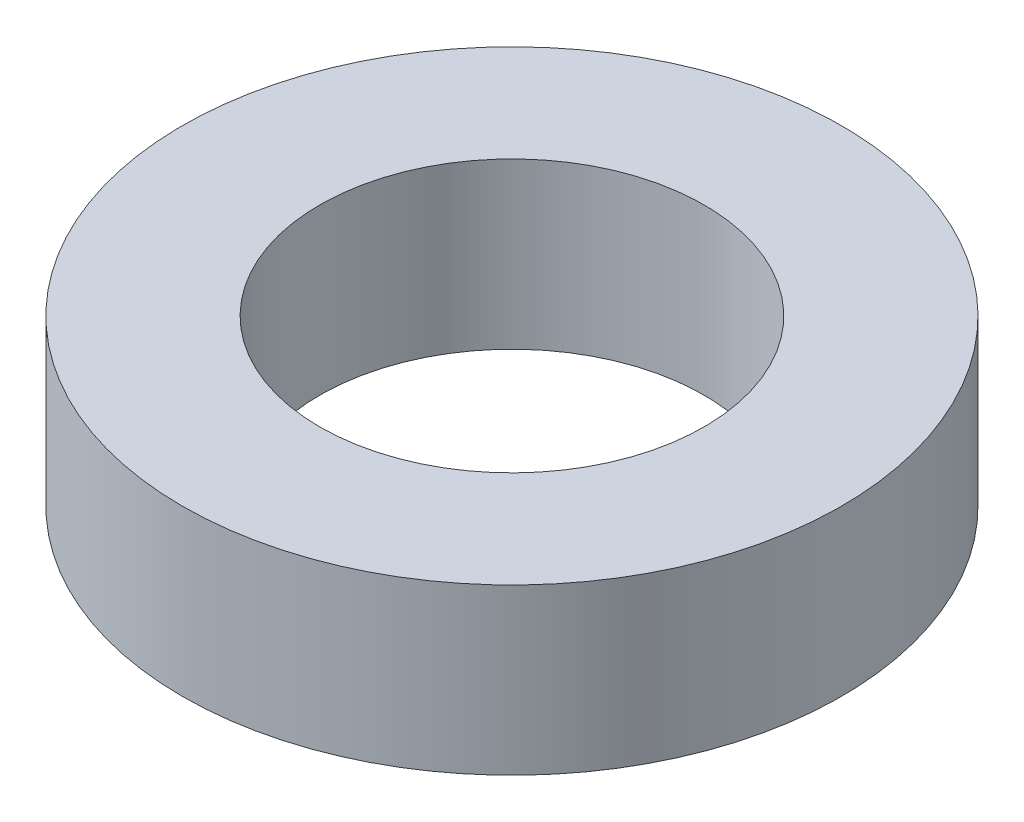
from build123d import *

# Parameters (mm, degrees)
SKETCH1_R           = 3
SKETCH1_R_2         = 1.75
BOSS_EXTRUDE1_DEPTH = 1.5


with BuildPart() as part:
    # Sketch1 → Boss-Extrude1 (new body)
    with BuildSketch(Plane(origin=(0, 0, 0), x_dir=(1, 0, 0), z_dir=(0, 1, 0))):
        Circle(SKETCH1_R)
        Circle(SKETCH1_R_2, mode=Mode.SUBTRACT)
    extrude(amount=BOSS_EXTRUDE1_DEPTH)


solid = part.part
